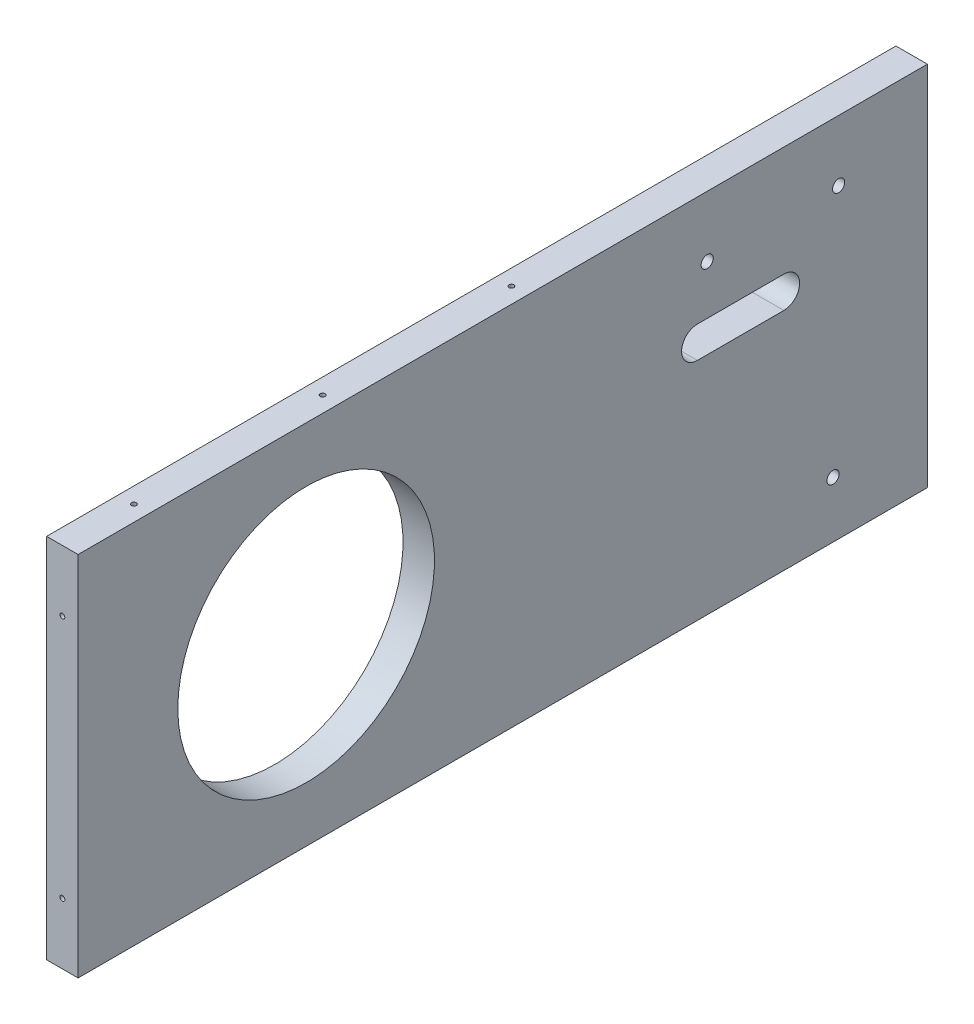
from build123d import *

# Parameters (mm, degrees)
SKETCH1_W                                 = 12.7
SKETCH1_H                                 = 148.079451403
BOSS_EXTRUDE1_DEPTH                       = 342.9
F_15_64_0_23438_DIAMETER_HOLE1_D          = 5.953252
F_15_64_0_23438_DIAMETER_HOLE1_DEPTH      = 12.7
F_15_64_0_23438_DIAMETER_HOLE1_TIP        = 1.788537341
F_15_64_0_23438_DIAMETER_HOLE3_D          = 5.953252
F_15_64_0_23438_DIAMETER_HOLE3_DEPTH      = 19.05
F_15_64_0_23438_DIAMETER_HOLE3_TIP        = 1.788537341
F_5_64_0_07813_DIAMETER_HOLE1_D           = 1.984502
F_5_64_0_07813_DIAMETER_HOLE1_DEPTH       = 38.1
F_5_64_0_07813_DIAMETER_HOLE1_CSINK_D     = 10.16
F_5_64_0_07813_DIAMETER_HOLE1_CSINK_ANGLE = 82
F_5_64_0_07813_DIAMETER_HOLE1_TIP         = 0.59620455
F_5_64_0_07813_DIAMETER_HOLE2_D           = 1.984502
F_5_64_0_07813_DIAMETER_HOLE2_DEPTH       = 38.1
F_5_64_0_07813_DIAMETER_HOLE2_CSINK_D     = 10.16
F_5_64_0_07813_DIAMETER_HOLE2_CSINK_ANGLE = 82
F_5_64_0_07813_DIAMETER_HOLE2_TIP         = 0.59620455
F_8_CLEARANCE_HOLE1_D                     = 4.9149
F_8_CLEARANCE_HOLE1_DEPTH                 = 12.7
CUT_EXTRUDE1_REACH                        = 14.7
SKETCH14_R                                = 51.814725701
CUT_EXTRUDE2_REACH                        = 14.7


with BuildPart() as part:
    # Sketch1 → Boss-Extrude1 (new body)
    with BuildSketch(Plane.XY):
        with Locations((-445.23025, -77.214725702)):
            Rectangle(SKETCH1_W, SKETCH1_H)
    extrude(amount=BOSS_EXTRUDE1_DEPTH)

    # 15/64 (0.23438) Diameter Hole1
    with Locations(Plane(origin=(-183.67375, 1933.375856936, -6.35), x_dir=(1, 0, 0), z_dir=(0, 0, -1))):
        with Locations((-261.5565, 1973.570719787), (-261.5565, 2010.590582637), (-261.5565, 2047.610445488), (-97.5233, 2112.481693679), (-97.5233, 2147.688356936), (-43.36415, 2120.065856936), (1.27, 2120.065856936), (45.90415, 2120.065856936), (100.0633, 2147.688356936), (100.0633, 2112.481693679), (264.0965, 2047.610445488), (264.0965, 1973.570719787)):
            Hole(F_15_64_0_23438_DIAMETER_HOLE1_D / 2, depth=F_15_64_0_23438_DIAMETER_HOLE1_DEPTH)
            with Locations((0, 0, -(F_15_64_0_23438_DIAMETER_HOLE1_DEPTH + F_15_64_0_23438_DIAMETER_HOLE1_TIP / 2))):  # 118° drill point
                Cone(0, F_15_64_0_23438_DIAMETER_HOLE1_D / 2, F_15_64_0_23438_DIAMETER_HOLE1_TIP, mode=Mode.SUBTRACT)

    # 15/64 (0.23438) Diameter Hole3
    with Locations(Plane(origin=(-182.40375, 1936.853954382, -6.35), x_dir=(1, 0, 0), z_dir=(0, 0, -1))):
        with Locations((-262.8265, 2051.088542934), (-262.8265, 2014.068680083), (-262.8265, 1977.048817232), (-98.7933, 2115.959791125), (-98.7933, 2151.166454382)):
            Hole(F_15_64_0_23438_DIAMETER_HOLE3_D / 2, depth=F_15_64_0_23438_DIAMETER_HOLE3_DEPTH)
            with Locations((0, 0, -(F_15_64_0_23438_DIAMETER_HOLE3_DEPTH + F_15_64_0_23438_DIAMETER_HOLE3_TIP / 2))):  # 118° drill point
                Cone(0, F_15_64_0_23438_DIAMETER_HOLE3_D / 2, F_15_64_0_23438_DIAMETER_HOLE3_TIP, mode=Mode.SUBTRACT)

    # 5/64 (0.07813) Diameter Hole1
    with Locations(Plane(origin=(-182.40375, 15.875, 6471.459863233), x_dir=(1, 0, 0), z_dir=(0, 1, 0))):
        with Locations((-262.8265, 6157.452363233), (-98.7933, 6157.452363233), (-262.8265, 6233.652363233), (-98.7933, 6233.652363233), (-262.8265, 6309.852363233), (-98.7933, 6309.852363233), (-267.97, 6119.034863233), (-115.57, 6119.034863233), (-1.27, 6119.034863233), (113.03, 6119.034863233), (265.43, 6119.034863233), (96.2533, 6309.852363233), (260.2865, 6309.852363233), (96.2533, 6233.652363233), (260.2865, 6233.652363233), (96.2533, 6157.452363233), (260.2865, 6157.452363233)):
            CounterSinkHole(F_5_64_0_07813_DIAMETER_HOLE1_D / 2, F_5_64_0_07813_DIAMETER_HOLE1_CSINK_D / 2, depth=F_5_64_0_07813_DIAMETER_HOLE1_DEPTH, counter_sink_angle=F_5_64_0_07813_DIAMETER_HOLE1_CSINK_ANGLE)
            with Locations((0, 0, -(F_5_64_0_07813_DIAMETER_HOLE1_DEPTH + F_5_64_0_07813_DIAMETER_HOLE1_TIP / 2))):  # 118° drill point
                Cone(0, F_5_64_0_07813_DIAMETER_HOLE1_D / 2, F_5_64_0_07813_DIAMETER_HOLE1_TIP, mode=Mode.SUBTRACT)

    # 5/64 (0.07813) Diameter Hole2
    with Locations(Plane(origin=(-182.40375, 1936.853954382, 361.95), x_dir=(-1, 0, 0), z_dir=(0, 0, 1))):
        with Locations((-263.392416364, 1965.434682144), (262.8265, 1964.708862949), (262.8265, 2063.428497217), (98.7933, 2131.851871048), (98.7933, 1978.393537715), (53.56098, 2123.543954382), (-53.56098, 2123.543954382), (-99.322089753, 1978.666800322), (-98.898757225, 2132.124549748), (-263.120086856, 2064.153940785)):
            CounterSinkHole(F_5_64_0_07813_DIAMETER_HOLE2_D / 2, F_5_64_0_07813_DIAMETER_HOLE2_CSINK_D / 2, depth=F_5_64_0_07813_DIAMETER_HOLE2_DEPTH, counter_sink_angle=F_5_64_0_07813_DIAMETER_HOLE2_CSINK_ANGLE)
            with Locations((0, 0, -(F_5_64_0_07813_DIAMETER_HOLE2_DEPTH + F_5_64_0_07813_DIAMETER_HOLE2_TIP / 2))):  # 118° drill point
                Cone(0, F_5_64_0_07813_DIAMETER_HOLE2_D / 2, F_5_64_0_07813_DIAMETER_HOLE2_TIP, mode=Mode.SUBTRACT)

    # #8 Clearance Hole1
    with Locations(Plane.ZY.offset(451.58025)):
        with Locations((88.9, -27.7495), (35.8275, -27.7495), (38.1, -128.5875)):
            Hole(F_8_CLEARANCE_HOLE1_D / 2, depth=F_8_CLEARANCE_HOLE1_DEPTH)

    # Sketch14 → Cut-Extrude1 (cut, up to next)
    with BuildSketch(Plane.ZY.offset(451.58025), mode=Mode.PRIVATE) as cut_extrude1_sk1:
        with Locations((250.825, -77.214725701)):
            Circle(SKETCH14_R)
    cut_extrude1_tool1 = extrude(cut_extrude1_sk1.sketch, amount=-CUT_EXTRUDE1_REACH, mode=Mode.PRIVATE) & part.part
    add(cut_extrude1_tool1.solids().sort_by_distance((-451.58025, -77.214726, 250.825))[0], mode=Mode.SUBTRACT)

    # Sketch15 → Cut-Extrude2 (cut, up to next)
    with BuildSketch(Plane.ZY.offset(451.58025), mode=Mode.PRIVATE) as cut_extrude2_sk1:
        with BuildLine():
            Line((92.8625, -60.322451403), (57.9375, -60.322451403))
            ThreePointArc((57.9375, -60.322451403), (51.5875, -53.972451403), (57.9375, -47.622451403))
            Line((57.9375, -47.622451403), (92.8625, -47.622451403))
            ThreePointArc((92.8625, -47.622451403), (99.2125, -53.972451403), (92.8625, -60.322451403))
        make_face()
    cut_extrude2_tool1 = extrude(cut_extrude2_sk1.sketch, amount=-CUT_EXTRUDE2_REACH, mode=Mode.PRIVATE) & part.part
    add(cut_extrude2_tool1.solids().sort_by_distance((-451.58025, -53.972451, 75.4))[0], mode=Mode.SUBTRACT)


solid = part.part
